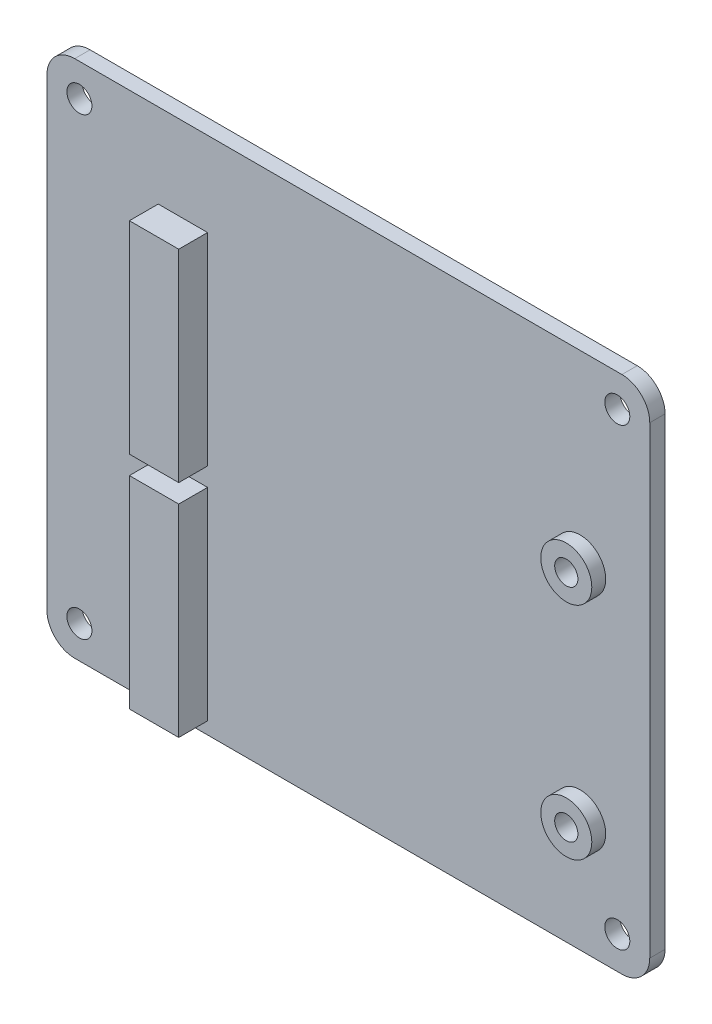
from build123d import *

# Parameters (mm, degrees)
EXTRUDE_1_DEPTH     = 1.65
SKETCH_2_R          = 1.35
CUT_EXTRUDE_1_DEPTH = 1.65
SKETCH_3_W          = 5.32
SKETCH_3_H          = 21.8
EXTRUDE_2_DEPTH     = 3.11
SKETCH_4_R          = 2.75
EXTRUDE_3_DEPTH     = 1.5
CUT_EXTRUDE_2_REACH = 5.15
SKETCH_5_R          = 1.25


with BuildPart() as part:
    # 草图1 → 凸台-拉伸1 (new body)
    with BuildSketch(Plane(origin=(23.590329777, 87.741111173, -201.321110376), x_dir=(1, 0, 0), z_dir=(0, 0, 1))):
        with BuildLine():
            Line((-93.354201199, 91.485679355), (-34.354201199, 91.485679355))
            ThreePointArc((-34.354201199, 91.485679355), (-32.232880856, 90.606999698), (-31.354201199, 88.485679355))
            Line((-31.354201199, 88.485679355), (-31.354201199, 38.485679355))
            ThreePointArc((-31.354201199, 38.485679355), (-32.232880856, 36.364359011), (-34.354201199, 35.485679355))
            Line((-34.354201199, 35.485679355), (-93.354201199, 35.485679355))
            ThreePointArc((-93.354201199, 35.485679355), (-95.475521543, 36.364359011), (-96.354201199, 38.485679355))
            Line((-96.354201199, 38.485679355), (-96.354201199, 88.485679355))
            ThreePointArc((-96.354201199, 88.485679355), (-95.475521543, 90.606999698), (-93.354201199, 91.485679355))
        make_face()
    extrude(amount=EXTRUDE_1_DEPTH)

    # 草图2 → 切除-拉伸1 (cut)
    with BuildSketch(Plane.XY.offset(-199.671110376)):
        with Locations((-69.263871422, 175.726790528)):
            Circle(SKETCH_2_R)
        with Locations((-11.263871422, 175.726790528)):
            Circle(SKETCH_2_R)
        with Locations((-69.263871422, 126.726790528)):
            Circle(SKETCH_2_R)
        with Locations((-11.263871422, 126.726790528)):
            Circle(SKETCH_2_R)
    extrude(amount=-CUT_EXTRUDE_1_DEPTH, mode=Mode.SUBTRACT)

    # 草图3 → 凸台-拉伸2 (add)
    with BuildSketch(Plane.XY.offset(-199.671110376)):
        with Locations((-58.103871422, 159.246790528)):
            Rectangle(SKETCH_3_W, SKETCH_3_H)
        with Locations((-58.103871422, 135.446790528)):
            Rectangle(SKETCH_3_W, SKETCH_3_H)
    extrude(amount=EXTRUDE_2_DEPTH)

    # 草图4 → 凸台-拉伸3 (add)
    with BuildSketch(Plane.XY.offset(-199.671110376)):
        with Locations((-15.263871422, 135.446790528)):
            Circle(SKETCH_4_R)
        with Locations((-15.263871422, 159.246790528)):
            Circle(SKETCH_4_R)
    extrude(amount=EXTRUDE_3_DEPTH)

    # 草图5 → 切除-拉伸2 (cut, up to next)
    with BuildSketch(Plane.XY.offset(-198.171110376), mode=Mode.PRIVATE) as cut_extrude_2_sk1:
        with Locations((-15.263871422, 159.246790528)):
            Circle(SKETCH_5_R)
    cut_extrude_2_tool1 = extrude(cut_extrude_2_sk1.sketch, amount=-CUT_EXTRUDE_2_REACH, mode=Mode.PRIVATE) & part.part
    add(cut_extrude_2_tool1.solids().sort_by_distance((-15.263871, 159.246791, -198.17111))[0], mode=Mode.SUBTRACT)
    # 草图5 → 切除-拉伸2 (cut, up to next)
    with BuildSketch(Plane.XY.offset(-198.171110376), mode=Mode.PRIVATE) as cut_extrude_2_sk2:
        with Locations((-15.263871422, 135.446790528)):
            Circle(SKETCH_5_R)
    cut_extrude_2_tool2 = extrude(cut_extrude_2_sk2.sketch, amount=-CUT_EXTRUDE_2_REACH, mode=Mode.PRIVATE) & part.part
    add(cut_extrude_2_tool2.solids().sort_by_distance((-15.263871, 135.446791, -198.17111))[0], mode=Mode.SUBTRACT)


solid = part.part
